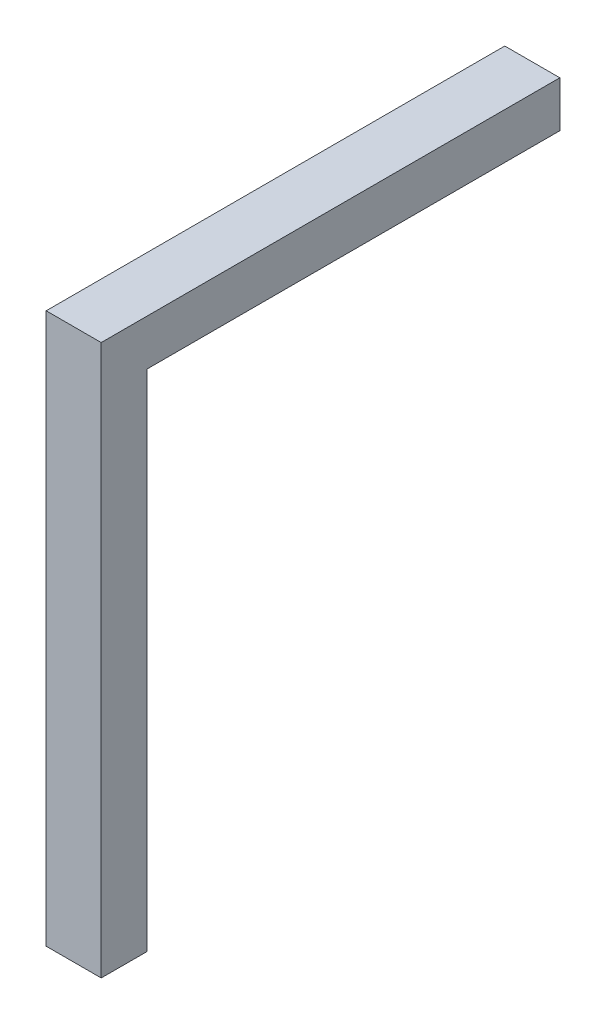
from build123d import *

# Parameters (mm, degrees)
BOSS_EXTRUDE1_DEPTH = 6


with BuildPart() as part:
    # Sketch1 → Boss-Extrude1 (new body)
    with BuildSketch(Plane(origin=(0, 0, 0), x_dir=(0, 0, -1), z_dir=(1, 0, 0))):
        Polygon((-10, 36.432160804), (-60, 36.432160804), (-60, -23.567839196), (-55, -23.567839196), (-55, 31.432160804), (-10, 31.432160804), align=None)
    extrude(amount=BOSS_EXTRUDE1_DEPTH)


solid = part.part
